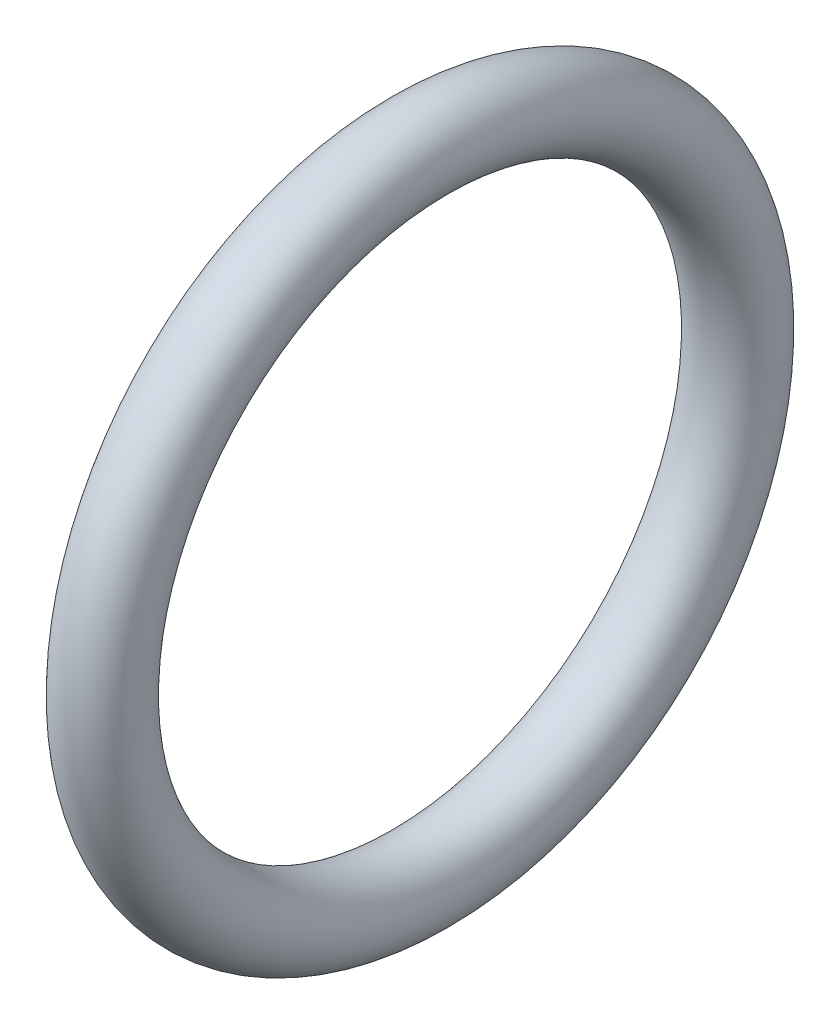
from build123d import *

# Parameters (mm, degrees)
SKETCH1_R = 0.5


with BuildPart() as part:
    # Sketch1 → Revolve1 (revolve)
    with BuildSketch(Plane.XY):
        with Locations((0, 4)):
            Circle(SKETCH1_R)
    revolve(axis=Axis((0, 0, 0), (-1, 0, 0)))


solid = part.part
